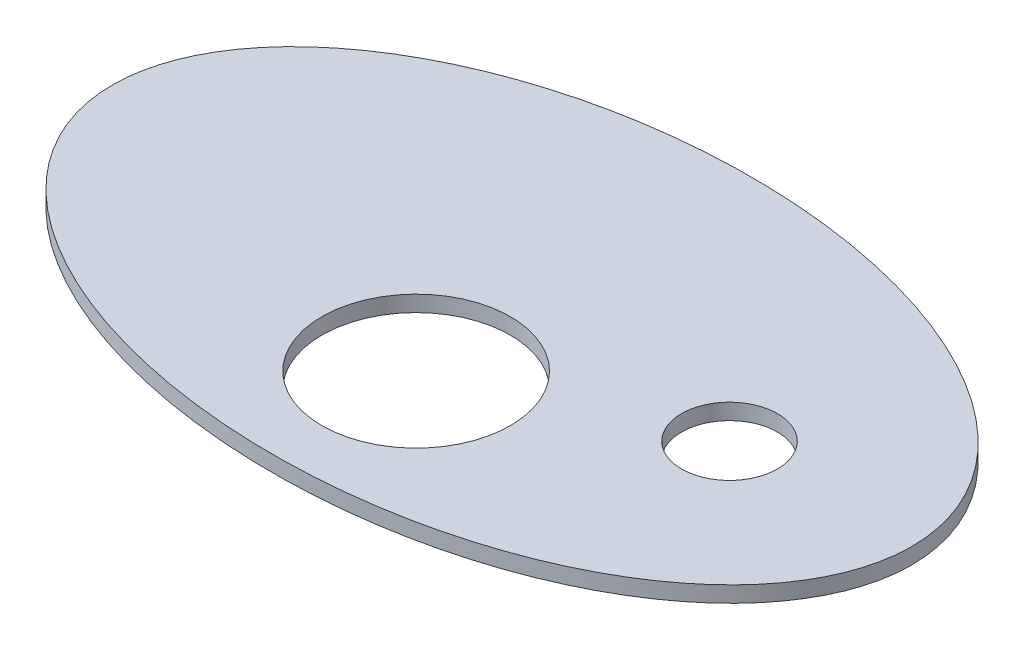
from build123d import *

# Parameters (mm, degrees)
SKETCH1_RX          = 125
SKETCH1_RY          = 75
BOSS_EXTRUDE1_DEPTH = 5
SKETCH2_R           = 29.5
SKETCH2_R_2         = 15
CUT_EXTRUDE1_DEPTH  = 5


with BuildPart() as part:
    # Sketch1 → Boss-Extrude1 (new body)
    with BuildSketch(Plane(origin=(0, 0, 0), x_dir=(1, 0, 0), z_dir=(0, 1, 0))):
        with Locations(Location((0, 0), (0, 0, 0))):
            Ellipse(SKETCH1_RX, SKETCH1_RY)
    extrude(amount=BOSS_EXTRUDE1_DEPTH)

    # Sketch2 → Cut-Extrude1 (cut)
    with BuildSketch(Plane(origin=(0, 5, 0), x_dir=(1, 0, 0), z_dir=(0, 1, 0))):
        with Locations((0, -30)):
            Circle(SKETCH2_R)
        with Locations((68, 0)):
            Circle(SKETCH2_R_2)
    extrude(amount=-CUT_EXTRUDE1_DEPTH, mode=Mode.SUBTRACT)


solid = part.part
